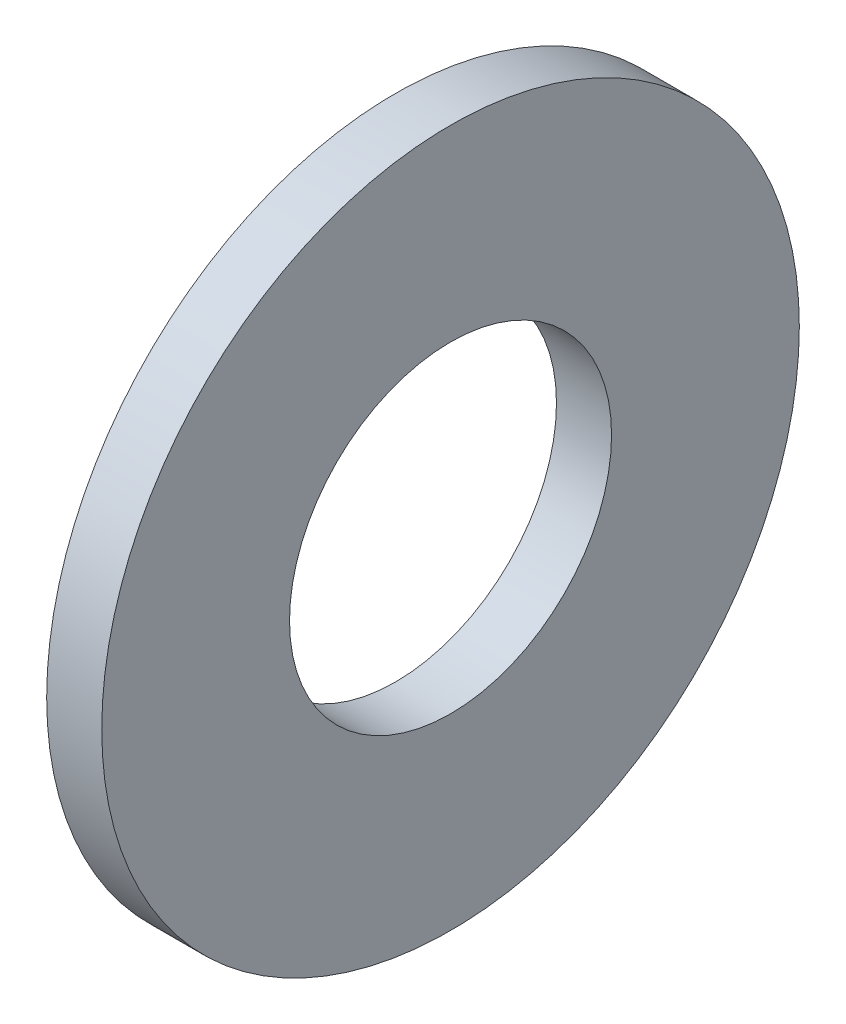
from build123d import *

# Parameters (mm, degrees)
SKETCH1_W = 3
SKETCH1_H = 10.228870078


with BuildPart() as part:
    # Sketch1 → Revolve1 (revolve)
    with BuildSketch(Plane.XY):
        with Locations((17.908906872, 11.791737839)):
            Rectangle(SKETCH1_W, SKETCH1_H)
    revolve(axis=Axis((-16.762687395, -2.093827122, 0), (1, 0, 0)))


solid = part.part
